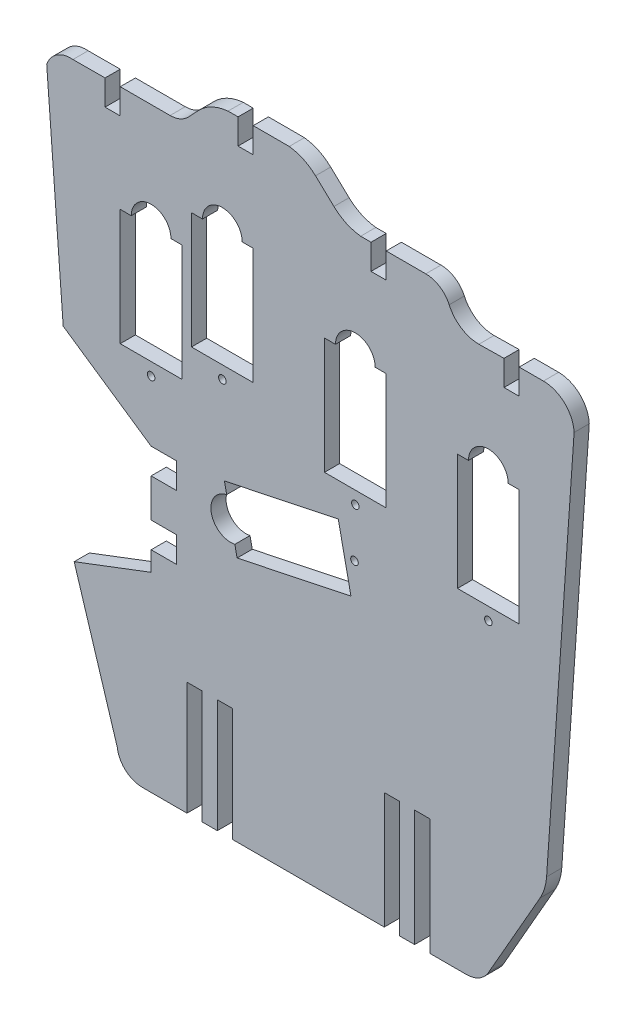
from build123d import *

# Parameters (mm, degrees)
SKETCH1_W           = 12.2
SKETCH1_H           = 23
BOSS_EXTRUDE1_DEPTH = 3
CUT_EXTRUDE2_DEPTH  = 4
SKETCH5_R           = 3.925
CUT_EXTRUDE3_DEPTH  = 4
SKETCH6_R           = 0.75
CUT_EXTRUDE4_DEPTH  = 4
SKETCH7_R           = 3.93
SKETCH7_R_2         = 0.75
CUT_EXTRUDE5_DEPTH  = 4
SKETCH8_R           = 0.75
CUT_EXTRUDE6_DEPTH  = 4


with BuildPart() as part:
    # Sketch1 → Boss-Extrude1 (new body)
    with BuildSketch(Plane.XY):
        with BuildLine():
            Line((22.600652844, 98.055778181), (24.552064, 100.123868682))
            ThreePointArc((24.552064, 100.123868682), (27.226414403, 102.085102355), (30.423169177, 102.967908395))
            Line((30.423169177, 102.967908395), (32.3981368, 102.967908395))
            Line((32.3981368, 102.967908395), (32.3981368, 97.967908395))
            Line((32.3981368, 97.967908395), (35.3981368, 97.967908395))
            Line((35.3981368, 97.967908395), (35.3981368, 102.967908395))
            Line((35.3981368, 102.967908395), (42.521983007, 102.967908395))
            ThreePointArc((42.521983007, 102.967908395), (45.313446231, 102.166024258), (47.714614303, 100.532109635))
            Line((47.714614303, 100.532109635), (51.351246918, 97.100651749))
            ThreePointArc((51.351246918, 97.100651749), (53.795711755, 95.446564433), (56.638770897, 94.65382999))
            Line((56.638770897, 94.65382999), (58.6881368, 94.65382999))
            Line((58.6881368, 94.65382999), (58.6881368, 89.65382999))
            Line((58.6881368, 89.65382999), (61.6881368, 89.65382999))
            Line((61.6881368, 89.65382999), (61.6881368, 94.65382999))
            Line((61.6881368, 94.65382999), (69.516671711, 94.65382999))
            ThreePointArc((69.516671711, 94.65382999), (72.270221934, 93.840698694), (74.140331494, 91.662187375))
            ThreePointArc((74.140331494, 91.662187375), (76.513167022, 88.89023599), (80.008265046, 87.842212737))
            Line((80.008265046, 87.842212737), (84.9781368, 87.921834161))
            Line((84.9781368, 87.921834161), (84.9781368, 82.921834161))
            Line((84.9781368, 82.921834161), (87.9781368, 82.921834161))
            Line((87.9781368, 82.921834161), (87.9781368, 87.921834161))
            Line((87.9781368, 87.921834161), (92.770707207, 87.921834161))
            ThreePointArc((92.770707207, 87.921834161), (96.955459046, 86.251143727), (98.839013483, 82.157786039))
            Line((98.839013483, 82.157786039), (93.399435569, 3.354416739))
            ThreePointArc((93.399435569, 3.354416739), (92.994237185, 1.145679097), (92.106398089, -0.916952583))
            Line((92.106398089, -0.916952583), (81.904303792, -18.77723742))
            ThreePointArc((81.904303792, -18.77723742), (80.072671375, -20.621586038), (77.562692027, -21.297235952))
            Line((77.562692027, -21.297235952), (70.304838359, -21.297235952))
            Line((70.304838359, -21.297235952), (70.304838359, 1.741579383))
            Line((70.304838359, 1.741579383), (67.304838359, 1.741579383))
            Line((67.304838359, 1.741579383), (67.304838359, -21.297235952))
            Line((67.304838359, -21.297235952), (64.304838359, -21.297235952))
            Line((64.304838359, -21.297235952), (64.304838359, 1.741579383))
            Line((64.304838359, 1.741579383), (61.304838359, 1.741579383))
            Line((61.304838359, 1.741579383), (61.304838359, -21.297235952))
            Line((61.304838359, -21.297235952), (31.304838359, -21.297235952))
            Line((31.304838359, -21.297235952), (31.304838359, 1.130887015))
            Line((31.304838359, 1.130887015), (28.304838359, 1.130887015))
            Line((28.304838359, 1.130887015), (28.304838359, -21.297235952))
            Line((28.304838359, -21.297235952), (25.304838359, -21.297235952))
            Line((25.304838359, -21.297235952), (25.304838359, 1.130887015))
            Line((25.304838359, 1.130887015), (22.304838359, 1.130887015))
            Line((22.304838359, 1.130887015), (22.304838359, -21.297235952))
            Line((22.304838359, -21.297235952), (13.483047429, -21.297235952))
            ThreePointArc((13.483047429, -21.297235952), (10.159531289, -20.032773458), (8.51699975, -16.878932137))
            Line((8.51699975, -16.878932137), (0, 10.609645279))
            Line((0, 10.609645279), (15.219519397, 16.399351506))
            Line((15.219519397, 16.399351506), (15.219519397, 20.261157087))
            Line((15.219519397, 20.261157087), (20.219519397, 20.261157087))
            Line((20.219519397, 20.261157087), (20.219519397, 25.341157087))
            Line((20.219519397, 25.341157087), (15.219519397, 25.341157087))
            Line((15.219519397, 25.341157087), (15.219519397, 32.909351506))
            Line((15.219519397, 32.909351506), (20.219519397, 32.909351506))
            Line((20.219519397, 32.909351506), (20.219519397, 37.989351506))
            Line((20.219519397, 37.989351506), (15.219519397, 37.989351506))
            Line((15.219519397, 37.989351506), (-2.165979283, 49.840454802))
            Line((-2.165979283, 49.840454802), (-5.425944103, 93.020454802))
            ThreePointArc((-5.425944103, 93.020454802), (-3.436216957, 95.650222165), (-0.241837421, 96.469142112))
            Line((-0.241837421, 96.469142112), (6.1081368, 96.487236066))
            Line((6.1081368, 96.487236066), (6.1081368, 91.487236066))
            Line((6.1081368, 91.487236066), (9.1081368, 91.487236066))
            Line((9.1081368, 91.487236066), (9.1081368, 96.487236066))
            Line((9.1081368, 96.487236066), (18.964020228, 96.487236066))
            ThreePointArc((18.964020228, 96.487236066), (20.944261448, 96.896087548), (22.600652844, 98.055778181))
        make_face()
        with Locations((81.8781368, 55.421834161)):
            Rectangle(SKETCH1_W, SKETCH1_H, mode=Mode.SUBTRACT)
        with Locations((55.5881368, 62.15382999)):
            Rectangle(SKETCH1_W, SKETCH1_H, mode=Mode.SUBTRACT)
        with Locations((29.2981368, 70.467908395)):
            Rectangle(SKETCH1_W, SKETCH1_H, mode=Mode.SUBTRACT)
        with Locations((15.2081368, 63.987236066)):
            Rectangle(SKETCH1_W, SKETCH1_H, mode=Mode.SUBTRACT)
    extrude(amount=BOSS_EXTRUDE1_DEPTH)

    # Sketch4 → Cut-Extrude2 (cut, through all)
    with BuildSketch(Plane(origin=(0, 0, 0), x_dir=(-1, 0, 0), z_dir=(0, 0, -1))):
        Polygon((-52.208167191, 44.022304868), (-29.701522137, 39.284063804), (-32.214850005, 27.345756427), (-54.72149506, 32.083997491), align=None)
    extrude(amount=-CUT_EXTRUDE2_DEPTH, mode=Mode.SUBTRACT)

    # Sketch5 → Cut-Extrude3 (cut, through all)
    with BuildSketch(Plane.XY.offset(3)):
        with Locations((15.2081368, 75.487236066)):
            Circle(SKETCH5_R)
        with Locations((29.2981368, 81.967908395)):
            Circle(SKETCH5_R)
        with Locations((55.5881368, 73.65382999)):
            Circle(SKETCH5_R)
        with Locations((81.8781368, 66.921834161)):
            Circle(SKETCH5_R)
    extrude(amount=-CUT_EXTRUDE3_DEPTH, mode=Mode.SUBTRACT)

    # Sketch6 → Cut-Extrude4 (cut, through all)
    with BuildSketch(Plane.XY.offset(3)):
        with Locations((15.2081368, 49.987236066)):
            Circle(SKETCH6_R)
        with Locations((29.2981368, 56.467908395)):
            Circle(SKETCH6_R)
        with Locations((55.5881368, 48.15382999)):
            Circle(SKETCH6_R)
        with Locations((81.8781368, 41.421834161)):
            Circle(SKETCH6_R)
    extrude(amount=-CUT_EXTRUDE4_DEPTH, mode=Mode.SUBTRACT)

    # Sketch7 → Cut-Extrude5 (cut, through all)
    with BuildSketch(Plane(origin=(0, 0, 0), x_dir=(-1, 0, 0), z_dir=(0, 0, -1))):
        with Locations((-30.958186071, 33.314910116)):
            Circle(SKETCH7_R)
        with Locations((-52.760024114, 36.18145487)):
            Circle(SKETCH7_R_2)
    extrude(amount=-CUT_EXTRUDE5_DEPTH, mode=Mode.SUBTRACT)

    # Sketch8 → Cut-Extrude6 (cut, through all)
    with BuildSketch(Plane.XY.offset(3)):
        with Locations((55.421930696, 38.465172142)):
            Circle(SKETCH8_R)
    extrude(amount=-CUT_EXTRUDE6_DEPTH, mode=Mode.SUBTRACT)


solid = part.part
